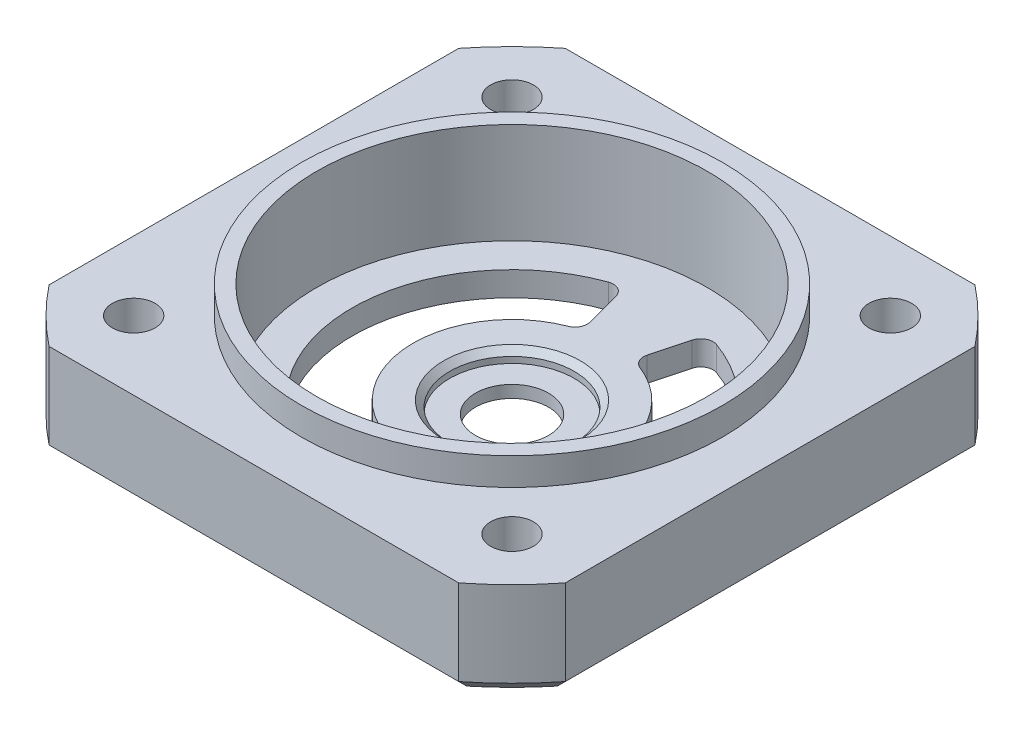
from build123d import *

# Parameters (mm, degrees)
SKETCH2_W           = 42.3
SKETCH2_H           = 42.3
BOSS_EXTRUDE1_DEPTH = 8
SKETCH5_R           = 29.910616844
SKETCH5_R_2         = 27
CUT_EXTRUDE4_DEPTH  = 9
SKETCH6_R           = 16
CUT_EXTRUDE7_DEPTH  = 7
SKETCH8_R           = 16
SKETCH8_R_2         = 5.1
BOSS_EXTRUDE3_DEPTH = 1
CUT_EXTRUDE8_DEPTH  = 3
FILLET1_R           = 1
SKETCH10_R          = 3
CUT_EXTRUDE9_DEPTH  = 2
SKETCH7_R           = 1.75
CUT_EXTRUDE6_DEPTH  = 9
CHAMFER4_SIZE       = 1
CHAMFER5_SIZE       = 2
CHAMFER6_SIZE       = 0.5
SKETCH11_R          = 17.25
SKETCH11_R_2        = 16
BOSS_EXTRUDE4_DEPTH = 2.25


with BuildPart() as part:
    # Sketch2 → Boss-Extrude1 (new body)
    with BuildSketch(Plane(origin=(0, 0, 0), x_dir=(1, 0, 0), z_dir=(0, 1, 0))):
        Rectangle(SKETCH2_W, SKETCH2_H)
    extrude(amount=BOSS_EXTRUDE1_DEPTH)

    # Sketch5 → Cut-Extrude4 (cut, through all)
    with BuildSketch(Plane(origin=(0, 8, 0), x_dir=(1, 0, 0), z_dir=(0, 1, 0))):
        Circle(SKETCH5_R)
        Circle(SKETCH5_R_2, mode=Mode.SUBTRACT)
    extrude(amount=-CUT_EXTRUDE4_DEPTH, mode=Mode.SUBTRACT)

    # Sketch6 → Cut-Extrude7 (cut)
    with BuildSketch(Plane(origin=(0, 8, 0), x_dir=(1, 0, 0), z_dir=(0, 1, 0))):
        Circle(SKETCH6_R)
    extrude(amount=-CUT_EXTRUDE7_DEPTH, mode=Mode.SUBTRACT)

    # Sketch8 → Boss-Extrude3 (add)
    with BuildSketch(Plane(origin=(0, 1, 0), x_dir=(1, 0, 0), z_dir=(0, 1, 0))):
        Circle(SKETCH8_R)
        Circle(SKETCH8_R_2, mode=Mode.SUBTRACT)
    extrude(amount=BOSS_EXTRUDE3_DEPTH)

    # Sketch9 → Cut-Extrude8 (cut, through all)
    with BuildSketch(Plane(origin=(0, 2, 0), x_dir=(1, 0, 0), z_dir=(0, 1, 0))):
        with BuildLine():
            Line((3.390529491, 12.653628324), (2.096434265, 7.823999193))
            ThreePointArc((2.096434265, 7.823999193), (8.1, 0), (2.096434265, -7.823999193))
            Line((2.096434265, -7.823999193), (3.390529491, -12.653628324))
            ThreePointArc((3.390529491, -12.653628324), (13.1, 0), (3.390529491, 12.653628324))
        make_face()
        with BuildLine():
            Line((-3.390529491, -12.653628324), (-2.096434265, -7.823999193))
            ThreePointArc((-2.096434265, -7.823999193), (-8.1, 0), (-2.096434265, 7.823999193))
            Line((-2.096434265, 7.823999193), (-3.390529491, 12.653628324))
            ThreePointArc((-3.390529491, 12.653628324), (-13.1, 0), (-3.390529491, -12.653628324))
        make_face()
    extrude(amount=-CUT_EXTRUDE8_DEPTH, mode=Mode.SUBTRACT)

    # Fillet1
    fillet1_edges = [part.edges().sort_by_distance(p)[0] for p in [
        (3.390529491, 1, -12.653628324),
        (3.390529491, 1, 12.653628324),
        (2.096434265, 1, 7.823999193),
        (2.096434265, 1, -7.823999193),
        (-2.096434265, 1, -7.823999193),
        (-2.096434265, 1, 7.823999193),
        (-3.390529491, 1, 12.653628324),
        (-3.390529491, 1, -12.653628324),
    ]]
    fillet(fillet1_edges, radius=FILLET1_R)

    # Sketch10 → Cut-Extrude9 (cut, through all)
    with BuildSketch(Plane(origin=(0, 1, 0), x_dir=(1, 0, 0), z_dir=(0, 1, 0))):
        Circle(SKETCH10_R)
    extrude(amount=-CUT_EXTRUDE9_DEPTH, mode=Mode.SUBTRACT)

    # Sketch7 → Cut-Extrude6 (cut, through all)
    with BuildSketch(Plane(origin=(0, 8, 0), x_dir=(1, 0, 0), z_dir=(0, 1, 0))):
        with Locations((-15.5, 15.5)):
            Circle(SKETCH7_R)
        with Locations((15.5, 15.5)):
            Circle(SKETCH7_R)
        with Locations((15.5, -15.5)):
            Circle(SKETCH7_R)
        with Locations((-15.5, -15.5)):
            Circle(SKETCH7_R)
    extrude(amount=-CUT_EXTRUDE6_DEPTH, mode=Mode.SUBTRACT)

    # Chamfer4
    chamfer4_edges = [part.edges().sort_by_distance(p)[0] for p in [
        (21.15, 0, 0),
        (0, 0, 21.15),
        (-21.15, 0, 0),
        (0, 0, -21.15),
        (-19.091883092, 0, 19.091883092),
        (-19.091883092, 0, -19.091883092),
        (19.091883092, 0, -19.091883092),
        (19.091883092, 0, 19.091883092),
    ]]
    chamfer(chamfer4_edges, length=CHAMFER4_SIZE)

    # Chamfer5
    chamfer5_edges = [part.edges().sort_by_distance(p)[0] for p in [
        (-17.25, 0, 15.5),
        (13.75, 0, 15.5),
        (13.75, 0, -15.5),
        (-17.25, 0, -15.5),
    ]]
    chamfer(chamfer5_edges, length=CHAMFER5_SIZE)

    # Chamfer6
    chamfer6_edges = [part.edges().sort_by_distance(p)[0] for p in [
        (-5.1, 2, 0),
    ]]
    chamfer(chamfer6_edges, length=CHAMFER6_SIZE)

    # Sketch11 → Boss-Extrude4 (add)
    with BuildSketch(Plane(origin=(0, 8, 0), x_dir=(1, 0, 0), z_dir=(0, 1, 0))):
        Circle(SKETCH11_R)
        Circle(SKETCH11_R_2, mode=Mode.SUBTRACT)
    extrude(amount=BOSS_EXTRUDE4_DEPTH)


solid = part.part
